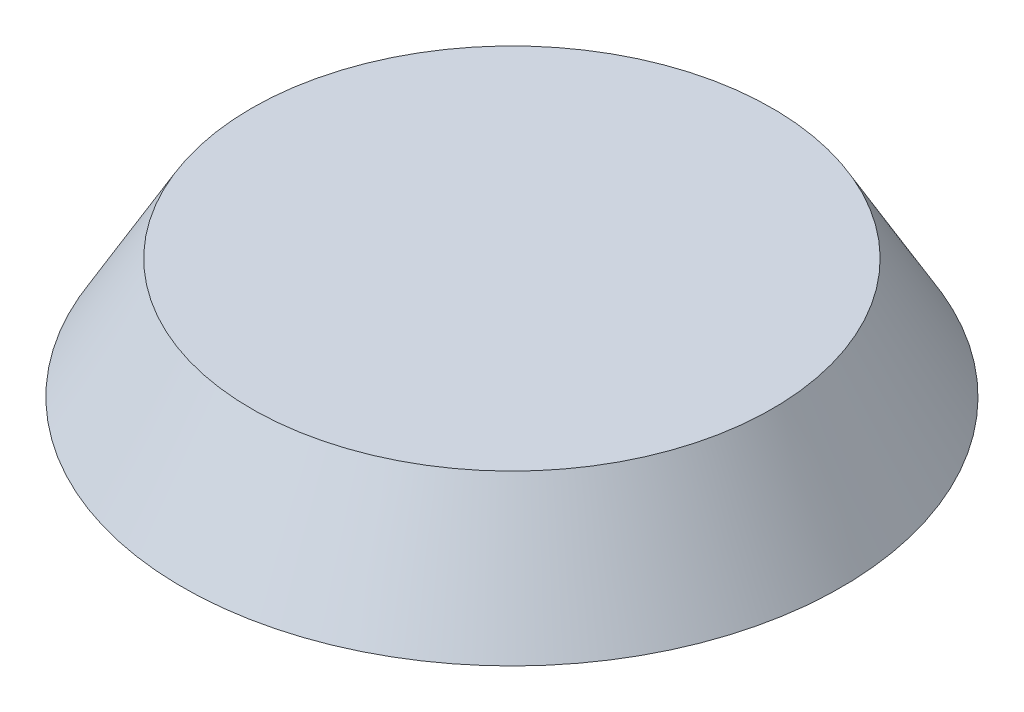
from build123d import *

# Parameters (mm, degrees)
BOSS_EXTRUDE1_DEPTH = 5
BOSS_EXTRUDE1_TAPER = 1


with BuildPart() as part:
    # Sketch2 → Boss-Extrude1 (new body)
    with BuildSketch(Plane(origin=(0, 0, 0), x_dir=(1, 0, 0), z_dir=(0, 1, 0))):
        with BuildLine():
            Line((-4.2, 18.6), (-4.2, 22.61327044))
            ThreePointArc((-4.2, 22.61327044), (-16.263455967, 16.263455967), (-22.61327044, 4.2))
            Line((-22.61327044, 4.2), (-18.6, 4.2))
            ThreePointArc((-18.6, 4.2), (-14.4, 0), (-18.6, -4.2))
            Line((-18.6, -4.2), (-22.61327044, -4.2))
            ThreePointArc((-22.61327044, -4.2), (-16.263455967, -16.263455967), (-4.2, -22.61327044))
            Line((-4.2, -22.61327044), (-4.2, -18.6))
            ThreePointArc((-4.2, -18.6), (0, -14.4), (4.2, -18.6))
            Line((4.2, -18.6), (4.2, -22.61327044))
            ThreePointArc((4.2, -22.61327044), (16.263455967, -16.263455967), (22.61327044, -4.2))
            Line((22.61327044, -4.2), (18.6, -4.2))
            ThreePointArc((18.6, -4.2), (14.4, 0), (18.6, 4.2))
            Line((18.6, 4.2), (22.61327044, 4.2))
            ThreePointArc((22.61327044, 4.2), (16.263455967, 16.263455967), (4.2, 22.61327044))
            Line((4.2, 22.61327044), (4.2, 18.6))
            ThreePointArc((4.2, 18.6), (0, 14.4), (-4.2, 18.6))
        make_face()
    extrude(amount=-BOSS_EXTRUDE1_DEPTH, taper=BOSS_EXTRUDE1_TAPER)

    # Sketch4 → Revolve1 (revolve)
    with BuildSketch(Plane.XY):
        Polygon((0, 0), (55, 0), (43.452994616, 20), (0, 20), align=None)
    revolve(axis=Axis((0, 20, 0), (0, -1, 0)))


solid = part.part
